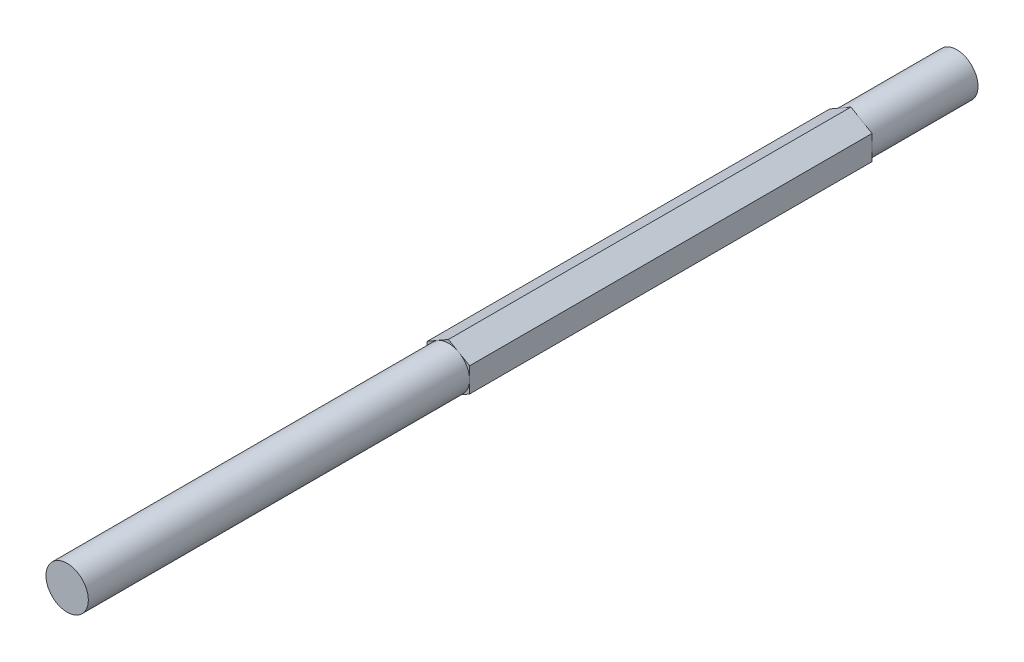
from build123d import *

# Parameters (mm, degrees)
BOSS_EXTRUDE1_DEPTH = 133.35
SKETCH3_OUTSIDE_W   = 35.09
SKETCH3_OUTSIDE_H   = 36.072
SKETCH3_OUTSIDE_R   = 3.175
CUT_EXTRUDE1_DEPTH  = 57.15
SKETCH4_OUTSIDE_W   = 35.09
SKETCH4_OUTSIDE_H   = 36.072
SKETCH4_OUTSIDE_R   = 3.175
CUT_EXTRUDE2_DEPTH  = 15.875


with BuildPart() as part:
    # Sketch2 → Boss-Extrude1 (new body)
    with BuildSketch(Plane.XY):
        Polygon((0, 3.666174209), (-3.175, 1.833087105), (-3.175, -1.833087105), (0, -3.666174209), (3.175, -1.833087105), (3.175, 1.833087105), align=None)
    extrude(amount=BOSS_EXTRUDE1_DEPTH)

    # Sketch3 outside → Cut-Extrude1 (cut)
    with BuildSketch(Plane.XY.offset(133.35)):
        Rectangle(SKETCH3_OUTSIDE_W, SKETCH3_OUTSIDE_H)
        Circle(SKETCH3_OUTSIDE_R, mode=Mode.SUBTRACT)
    extrude(amount=-CUT_EXTRUDE1_DEPTH, mode=Mode.SUBTRACT)

    # Sketch4 outside → Cut-Extrude2 (cut)
    with BuildSketch(Plane(origin=(0, 0, 0), x_dir=(-1, 0, 0), z_dir=(0, 0, -1))):
        Rectangle(SKETCH4_OUTSIDE_W, SKETCH4_OUTSIDE_H)
        Circle(SKETCH4_OUTSIDE_R, mode=Mode.SUBTRACT)
    extrude(amount=-CUT_EXTRUDE2_DEPTH, mode=Mode.SUBTRACT)


solid = part.part
